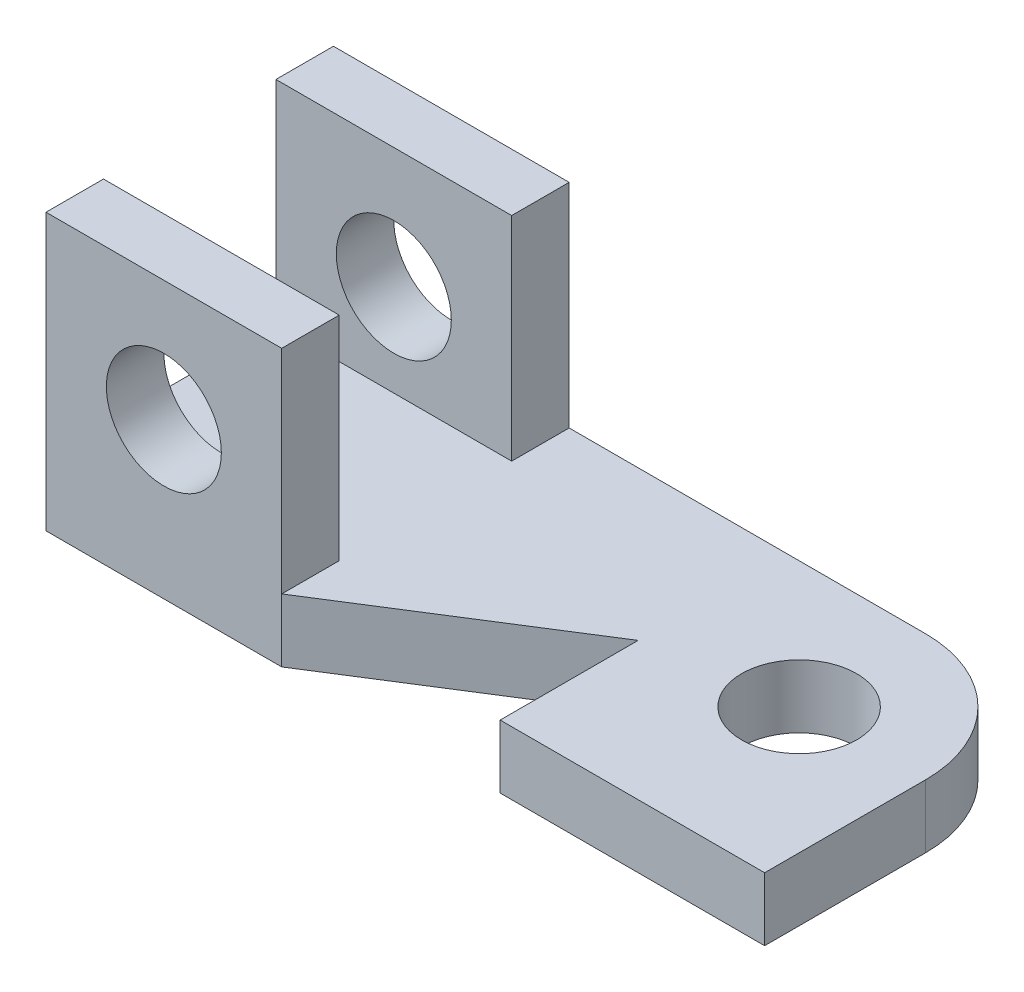
from build123d import *

# Parameters (mm, degrees)
BOSS_EXTRUDE1_DEPTH = 11
SKETCH2_R           = 10
CUT_EXTRUDE1_DEPTH  = 12
SKETCH3_W           = 41
SKETCH3_H           = 10
BOSS_EXTRUDE2_DEPTH = 37
SKETCH4_R           = 10
CUT_EXTRUDE2_DEPTH  = 51
FILLET4_R           = 22


with BuildPart() as part:
    # Sketch1 → Boss-Extrude1 (new body)
    with BuildSketch(Plane(origin=(0, 0, 0), x_dir=(1, 0, 0), z_dir=(0, 1, 0))):
        Polygon((16.5, -25), (62.5, -25), (62.5, 25), (-62.5, 25), (-62.5, -25), (-21.5, -25), (16.5, -1), align=None)
    extrude(amount=BOSS_EXTRUDE1_DEPTH)

    # Sketch2 → Cut-Extrude1 (cut, through all)
    with BuildSketch(Plane(origin=(0, 11, 0), x_dir=(1, 0, 0), z_dir=(0, 1, 0))):
        with Locations((40.5, 3)):
            Circle(SKETCH2_R)
    extrude(amount=-CUT_EXTRUDE1_DEPTH, mode=Mode.SUBTRACT)

    # Sketch3 → Boss-Extrude2 (add)
    with BuildSketch(Plane(origin=(0, 11, 0), x_dir=(1, 0, 0), z_dir=(0, 1, 0))):
        with Locations((-42, 20)):
            Rectangle(SKETCH3_W, SKETCH3_H)
        with Locations((-42, -20)):
            Rectangle(SKETCH3_W, SKETCH3_H)
    extrude(amount=BOSS_EXTRUDE2_DEPTH)

    # Sketch4 → Cut-Extrude2 (cut, through all)
    with BuildSketch(Plane.XY.offset(25)):
        with Locations((-42, 27)):
            Circle(SKETCH4_R)
    extrude(amount=-CUT_EXTRUDE2_DEPTH, mode=Mode.SUBTRACT)

    # Fillet4
    fillet4_edges = [part.edges().sort_by_distance(p)[0] for p in [
        (62.5, 5.5, -25),
    ]]
    fillet(fillet4_edges, radius=FILLET4_R)


solid = part.part
